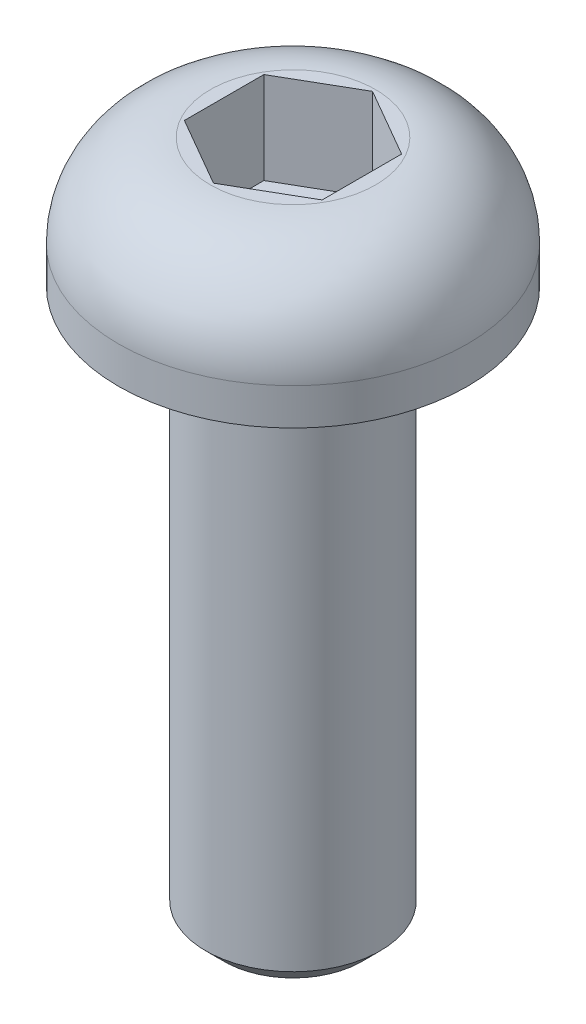
from build123d import *

# Parameters (mm, degrees)
SKETCH_1_R          = 1.9
EXTRUDE_1_DEPTH     = 1.4
CUT_EXTRUDE_1_DEPTH = 1
FILLET_1_R          = 1
SKETCH_3_R          = 0.95
EXTRUDE_2_DEPTH     = 6
CHAMFER_1_SIZE      = 0.2


with BuildPart() as part:
    # 草图1 → 凸台-拉伸1 (new body)
    with BuildSketch(Plane(origin=(0, 0, 0), x_dir=(1, 0, 0), z_dir=(0, 1, 0))):
        Circle(SKETCH_1_R)
    extrude(amount=EXTRUDE_1_DEPTH)

    # 草图2 → 切除-拉伸1 (cut)
    with BuildSketch(Plane(origin=(0, 1.4, 0), x_dir=(1, 0, 0), z_dir=(0, 1, 0))):
        Polygon((0, -0.866025404), (0.75, -0.433012702), (0.75, 0.433012702), (0, 0.866025404), (-0.75, 0.433012702), (-0.75, -0.433012702), align=None)
    extrude(amount=-CUT_EXTRUDE_1_DEPTH, mode=Mode.SUBTRACT)

    # 圆角1
    fillet_1_edges = [part.edges().sort_by_distance(p)[0] for p in [
        (-1.9, 1.4, 0),
    ]]
    fillet(fillet_1_edges, radius=FILLET_1_R)

    # 草图3 → 凸台-拉伸2 (add)
    with BuildSketch(Plane.XZ):
        Circle(SKETCH_3_R)
    extrude(amount=EXTRUDE_2_DEPTH)

    # 倒角1
    chamfer_1_edges = [part.edges().sort_by_distance(p)[0] for p in [
        (-0.95, -6, 0),
    ]]
    chamfer(chamfer_1_edges, length=CHAMFER_1_SIZE)


solid = part.part
